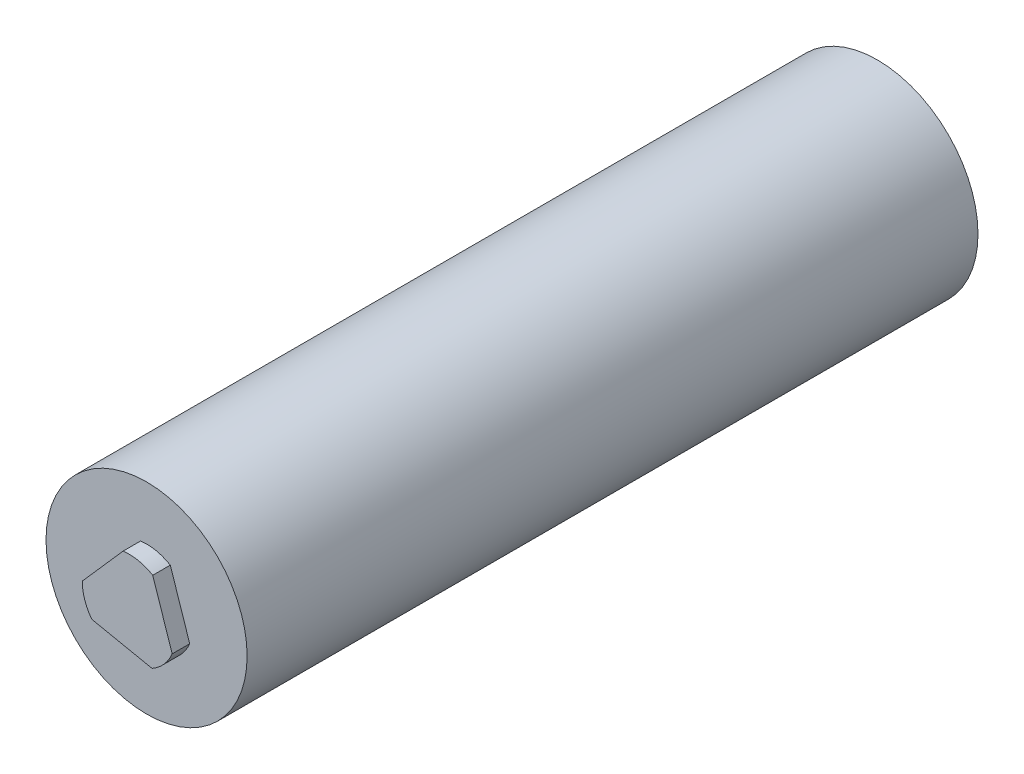
from build123d import *

# Parameters (mm, degrees)
SKETCH_1_R          = 8.6
EXTRUDE_1_DEPTH     = 64
SKETCH_2_OUTSIDE_W  = 32.894
SKETCH_2_OUTSIDE_H  = 32.894
CUT_EXTRUDE_1_DEPTH = 1.5


with BuildPart() as part:
    # Эскиз1 → Бобышка-Вытянуть1 (new body)
    with BuildSketch(Plane.XY):
        Circle(SKETCH_1_R)
    extrude(amount=EXTRUDE_1_DEPTH)

    # Эскиз2 outside → Вырез-Вытянуть1 (cut)
    with BuildSketch(Plane.XY.offset(64)):
        Rectangle(SKETCH_2_OUTSIDE_W, SKETCH_2_OUTSIDE_H)
        with BuildLine():
            Line((2.028187196, 3.4476741), (3.689688099, -1.544733546))
            ThreePointArc((3.689688099, -1.544733546), (2.991550535, -2.655301376), (1.971679756, -3.480298685))
            Line((1.971679756, -3.480298685), (-3.182622543, -2.422996853))
            ThreePointArc((-3.182622543, -2.422996853), (-3.790151064, -1.278575346), (-4, 0))
            Line((-4, 0), (-0.507065556, 3.967730399))
            ThreePointArc((-0.507065556, 3.967730399), (0.803783179, 3.918409448), (2.028187196, 3.4476741))
        make_face(mode=Mode.SUBTRACT)
    extrude(amount=-CUT_EXTRUDE_1_DEPTH, mode=Mode.SUBTRACT)


solid = part.part
